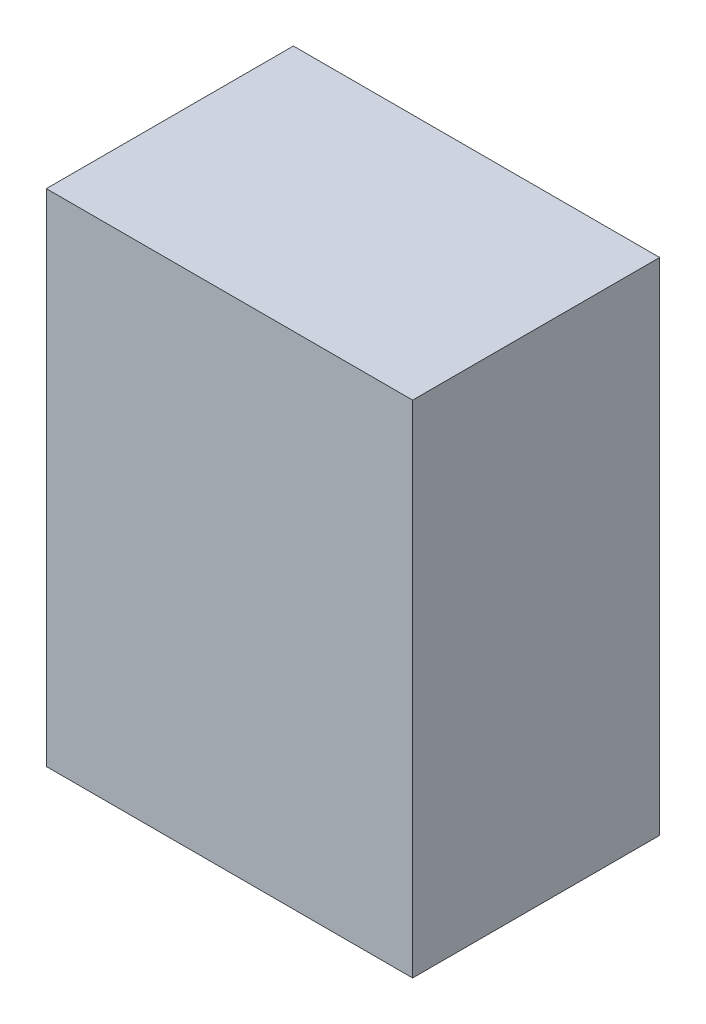
from build123d import *

# Parameters (mm, degrees)
SKETCH1_W           = 172
SKETCH1_H           = 115.999999902
BOSS_EXTRUDE1_DEPTH = 235


with BuildPart() as part:
    # Sketch1 → Boss-Extrude1 (new body)
    with BuildSketch(Plane(origin=(0, 0, 0), x_dir=(1, 0, 0), z_dir=(0, 1, 0))):
        Rectangle(SKETCH1_W, SKETCH1_H)
    extrude(amount=BOSS_EXTRUDE1_DEPTH)


solid = part.part
